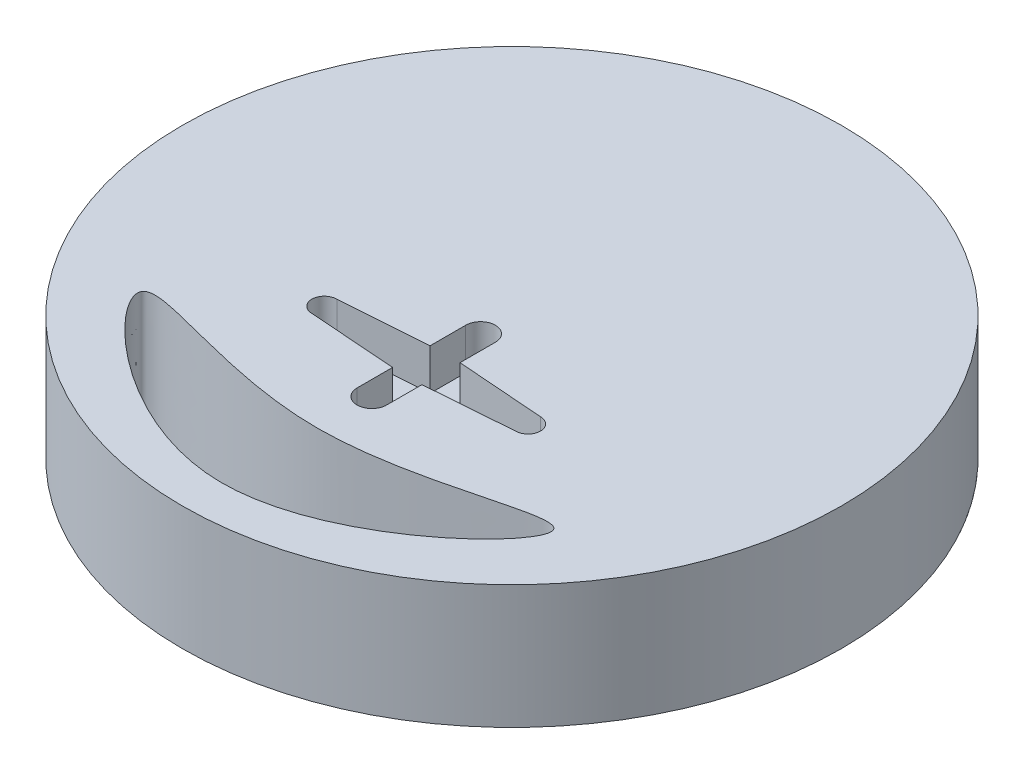
from build123d import *

# Parameters (mm, degrees)
SKETCH1_R               = 50.8
BOSS_EXTRUDE1_DEPTH     = 19.05
CUT_EXTRUDE1_DEPTH      = 6.35
CUT_EXTRUDE2_DEPTH      = 20.05
BOSS_EXTRUDE2_DEPTH     = 19.05
BOSS_EXTRUDE2_DRAFT     = 25
SKETCH6_R               = 7.62
CUT_EXTRUDE3_DEPTH      = 51.8000001
CUT_EXTRUDE3_DEPTH_BACK = 51.8000001


with BuildPart() as part:
    # Sketch1 → Boss-Extrude1 (new body)
    with BuildSketch(Plane(origin=(0, 0, 0), x_dir=(1, 0, 0), z_dir=(0, 1, 0))):
        Circle(SKETCH1_R)
    extrude(amount=BOSS_EXTRUDE1_DEPTH)

    # Sketch2 → Cut-Extrude1 (cut)
    with BuildSketch(Plane(origin=(0, 19.05, 0), x_dir=(1, 0, 0), z_dir=(0, 1, 0))):
        with BuildLine():
            Line((-15.6972, -11.290296429), (-2.281933688, -10.319915476))
            Line((-2.281933688, -10.319915476), (-2.281933688, -4.830552162))
            ThreePointArc((-2.281933688, -4.830552162), (0, -2.548618474), (2.281933688, -4.830552162))
            Line((2.281933688, -4.830552162), (2.281933688, -10.27350561))
            Line((2.281933688, -10.27350561), (15.6972, -11.290296429))
            ThreePointArc((15.6972, -11.290296429), (17.614394741, -13.20749117), (15.6972, -15.124685911))
            Line((15.6972, -15.124685911), (2.281933688, -16.141476731))
            Line((2.281933688, -16.141476731), (2.281933688, -21.584430178))
            ThreePointArc((2.281933688, -21.584430178), (0, -23.866363866), (-2.281933688, -21.584430178))
            Line((-2.281933688, -21.584430178), (-2.281933688, -16.095066864))
            Line((-2.281933688, -16.095066864), (-15.6972, -15.124685911))
            ThreePointArc((-15.6972, -15.124685911), (-17.614394741, -13.20749117), (-15.6972, -11.290296429))
        make_face()
    extrude(amount=-CUT_EXTRUDE1_DEPTH, mode=Mode.SUBTRACT)

    # Sketch3 → Cut-Extrude2 (cut, through all)
    with BuildSketch(Plane(origin=(0, 19.05, 0), x_dir=(1, 0, 0), z_dir=(0, 1, 0))):
        with BuildLine():
            add(Edge.make_bspline(
                [(-31.75, -25.323325498), (-33.428426621, -28.350329476), (0, -61.001077706), (47.854748089, -14.259621723), (0, -37.299148342), (-30.301321469, -22.710666938), (-31.75, -25.323325498)],
                knots=[0, 0, 0, 0, 0.268367474, 0.536734948, 0.768367474, 1, 1, 1, 1], degree=3))
        make_face()
    extrude(amount=-CUT_EXTRUDE2_DEPTH, mode=Mode.SUBTRACT)


with BuildPart() as body_2:
    # Sketch4 → Boss-Extrude2 (with draft: the straight prism first)
    with BuildSketch(Plane.XZ):
        with BuildLine():
            ThreePointArc((-44.437877263, -24.615342053), (0, -50.8), (44.437877263, -24.615342053))
            Line((44.437877263, -24.615342053), (25.387877263, -24.615342053))
            Line((25.387877263, -24.615342053), (14.224, 16.919953551))
            Line((14.224, 16.919953551), (-12.7, 16.919953551))
            Line((-12.7, 16.919953551), (-25.387877263, -24.615342053))
            Line((-25.387877263, -24.615342053), (-44.437877263, -24.615342053))
        make_face()
    extrude(amount=BOSS_EXTRUDE2_DEPTH)
    # Boss-Extrude2: the draft: its side faces are tilted about the plane it starts from
    boss_extrude2_sides = [body_2.faces().sort_by_distance(p)[0] for p in [
        (0, -9.525, -50.8),
        (34.912877263, -9.525, -24.615342053),
        (19.805938631, -9.525, -3.847694251),
        (0.762, -9.525, 16.919953551),
        (-19.043938631, -9.525, -3.847694251),
        (-34.912877263, -9.525, -24.615342053),
    ]]
    draft(boss_extrude2_sides, Plane.XZ, BOSS_EXTRUDE2_DRAFT)

    # Sketch6 → Cut-Extrude3 (cut, two sides)
    with BuildSketch(Plane.XY) as cut_extrude3_sk:
        with Locations((0, -10.16)):
            Circle(SKETCH6_R)
    extrude(amount=CUT_EXTRUDE3_DEPTH, mode=Mode.SUBTRACT)
    extrude(cut_extrude3_sk.sketch, amount=-CUT_EXTRUDE3_DEPTH_BACK, mode=Mode.SUBTRACT)


solid = Compound([part.part, body_2.part])
